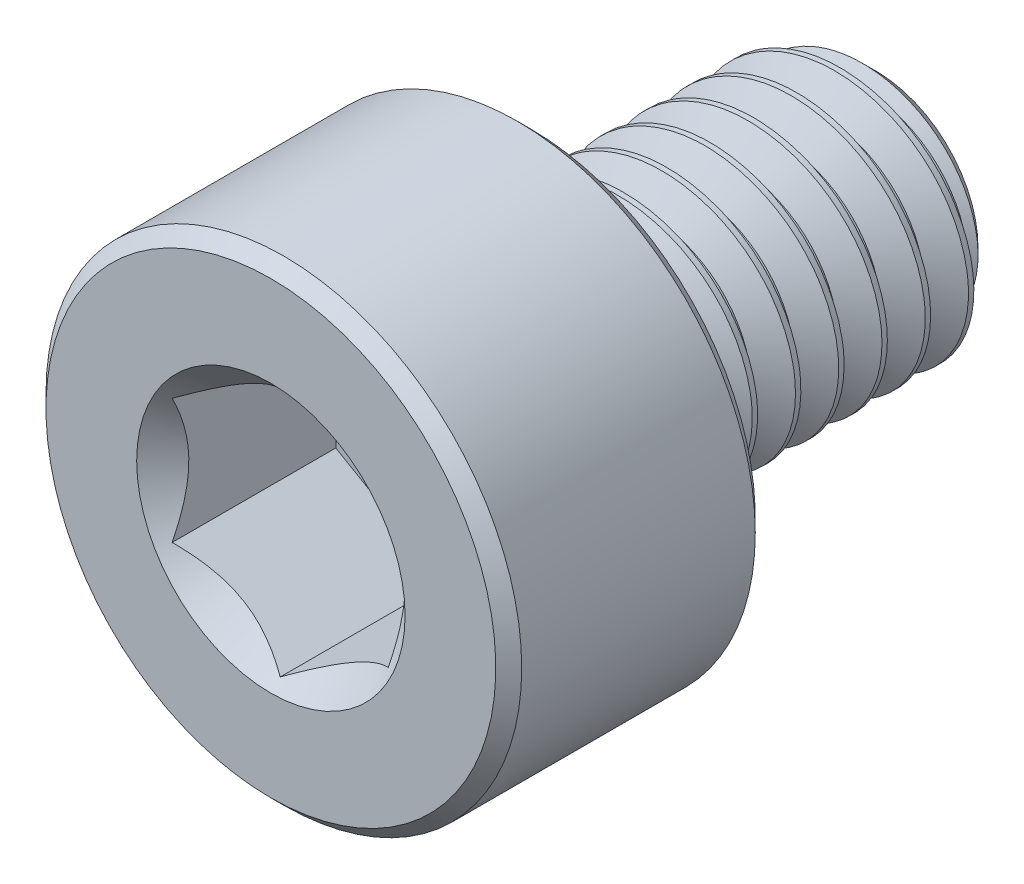
from build123d import *

# Parameters (mm, degrees)
CUT_EXTRUDE1_DEPTH     = 2
SKETCH4_R              = 1.5516288484471188
CUT_EXTRUDE2_DEPTH     = 1.5
CUT_EXTRUDE2_DRAFT     = -45.0000000000001
SPLIT1_SURFACE_1_BACK  = 11.464
SPLIT1_SURFACE_1_DEPTH = 22.928
SPLIT1_SURFACE_2_BACK  = 11.464
SPLIT1_SURFACE_2_DEPTH = 22.928
CUT_SWEEP1_PITCH       = 0.49999999999999917
CUT_SWEEP1_HEIGHT      = 4.5000000000000036
CUT_SWEEP1_RADIUS      = 1.5000000000000004
CUT_SWEEP1_START_ANGLE = 89.99999999999979


with BuildPart() as part:
    # Sketch2 → Revolve1 (revolve)
    with BuildSketch(Plane(origin=(0, 0, 0), x_dir=(0, 0, -1), z_dir=(1, 0, 0))):
        with BuildLine():
            Line((-3.4999999999999996, 0), (-3.4999999999999996, 2.6))
            Line((-3.4999999999999996, 2.6), (-3.3500000000000005, 2.75))
            Line((-3.3500000000000005, 2.75), (-0.6500000000000004, 2.75))
            Line((-0.6500000000000004, 2.75), (-0.5000000000000004, 2.6))
            Line((-0.5000000000000004, 2.6), (-0.4999999999999987, 1.6500000000000012))
            ThreePointArc((-0.4999999999999987, 1.6500000000000012), (-0.4560660171779805, 1.5439339828220187), (-0.34999999999999787, 1.5000000000000013))
            Line((-0.34999999999999787, 1.5000000000000013), (3.1752404735808337, 1.5))
            Line((3.1752404735808337, 1.5), (3.4999999999999996, 1.1752404735808353))
            Line((3.4999999999999996, 1.1752404735808353), (3.4999999999999996, 0))
            Line((3.4999999999999996, 0), (-3.4999999999999996, 0))
        make_face()
    revolve(axis=Axis((0, 0, -3.4999999999999996), (0, 0, 1)))

    # Sketch3 → Cut-Extrude1 (cut)
    with BuildSketch(Plane.XY.offset(3.4999999999999996)):
        Polygon((1.25, -0.7216878364870324), (1.25, 0.7216878364870322), (-3.1e-16, 1.4433756729740643), (-1.2499999999999998, 0.7216878364870319), (-1.2499999999999998, -0.7216878364870324), (7.6e-16, -1.4433756729740648), align=None)
    extrude(amount=-CUT_EXTRUDE1_DEPTH, mode=Mode.SUBTRACT)


with BuildPart() as cut_extrude2_tool:
    # Sketch4 → Cut-Extrude2 (with draft: the straight prism first)
    with BuildSketch(Plane.XY.offset(3.4999999999999996)):
        Circle(SKETCH4_R)
    extrude(amount=-CUT_EXTRUDE2_DEPTH)
    # Cut-Extrude2: the draft: its side faces are tilted about the plane it starts from
    cut_extrude2_sides = [cut_extrude2_tool.faces().sort_by_distance(p)[0] for p in [
        (-1.551628848, 0, 2.75),
    ]]
    draft(cut_extrude2_sides, Plane.XY.offset(3.4999999999999996), CUT_EXTRUDE2_DRAFT)


with BuildPart() as part_1:
    add(part.part)

    # Cut-Extrude2: cut by cut_extrude2_tool
    add(cut_extrude2_tool.part, mode=Mode.SUBTRACT)


with BuildPart() as body_2:
    # Split1: the piece behind the surface
    add(part_1.part)
    # Split1 surface: a surface, the sketch's curves swept straight by 22.928 mm
    with BuildLine(Plane(origin=(0, 0, 0), x_dir=(0, 0, -1), z_dir=(1, 0, 0)).offset(-SPLIT1_SURFACE_1_BACK), mode=Mode.PRIVATE) as split1_surface_1_path:
        Line((-0.34999999999999787, -2.75), (-0.34999999999999787, 2.75))
    split1_surface_1 = Shell.extrude(split1_surface_1_path.wire(), (1 * SPLIT1_SURFACE_1_DEPTH, 0 * SPLIT1_SURFACE_1_DEPTH, 0 * SPLIT1_SURFACE_1_DEPTH))
    split(bisect_by=split1_surface_1, keep=Keep.BOTTOM)

    # Cut-Sweep1: sweep along a helix
    with BuildLine() as cut_sweep1_path:
        add(Helix(CUT_SWEEP1_PITCH, CUT_SWEEP1_HEIGHT, CUT_SWEEP1_RADIUS, center=(0, 0, -3.5), direction=(0, 0, 1), mode=Mode.PRIVATE).rotate(Axis((0, 0, -3.5), (0, 0, 1)), CUT_SWEEP1_START_ANGLE))
    # Sketch7 → Cut-Sweep1 (sweep, cut)
    with BuildSketch(Plane(origin=(0, 0, 0), x_dir=(0, 0, -1), z_dir=(1, 0, 0))):
        Polygon((3.484375000000005, 1.5270632938682633), (3.953124999999993, 1.5270632938682633), (3.7499999999999982, 1.1752404735808353), (3.6874999999999982, 1.1752404735808353), align=None)
    sweep(path=cut_sweep1_path.line, is_frenet=True, mode=Mode.SUBTRACT)


with BuildPart() as part_2:
    add(part_1.part)

    # Split1: split by a surface, the side it looks to stays
    # Split1 surface: a surface, the sketch's curves swept straight by 22.928 mm
    with BuildLine(Plane(origin=(0, 0, 0), x_dir=(0, 0, -1), z_dir=(1, 0, 0)).offset(-SPLIT1_SURFACE_2_BACK), mode=Mode.PRIVATE) as split1_surface_2_path:
        Line((-0.34999999999999787, -2.75), (-0.34999999999999787, 2.75))
    split1_surface_2 = Shell.extrude(split1_surface_2_path.wire(), (1 * SPLIT1_SURFACE_2_DEPTH, 0 * SPLIT1_SURFACE_2_DEPTH, 0 * SPLIT1_SURFACE_2_DEPTH))
    split(bisect_by=split1_surface_2, keep=Keep.TOP)

    add(body_2.part)  # Revolve2 merges body 2
    # Sketch8 → Revolve2 (revolve)
    with BuildSketch(Plane(origin=(0, 0, 0), x_dir=(0, 0, -1), z_dir=(1, 0, 0))):
        Polygon((-0.4999999999999987, 4e-17), (-0.4999999999999987, 1.5), (-0.34999999999999787, 1.5), (0.516025403784451, 1.8e-16), align=None)
    revolve(axis=Axis((0, 1.8e-16, -0.516025403784451), (0, -1.4e-16, 1)))


solid = part_2.part
